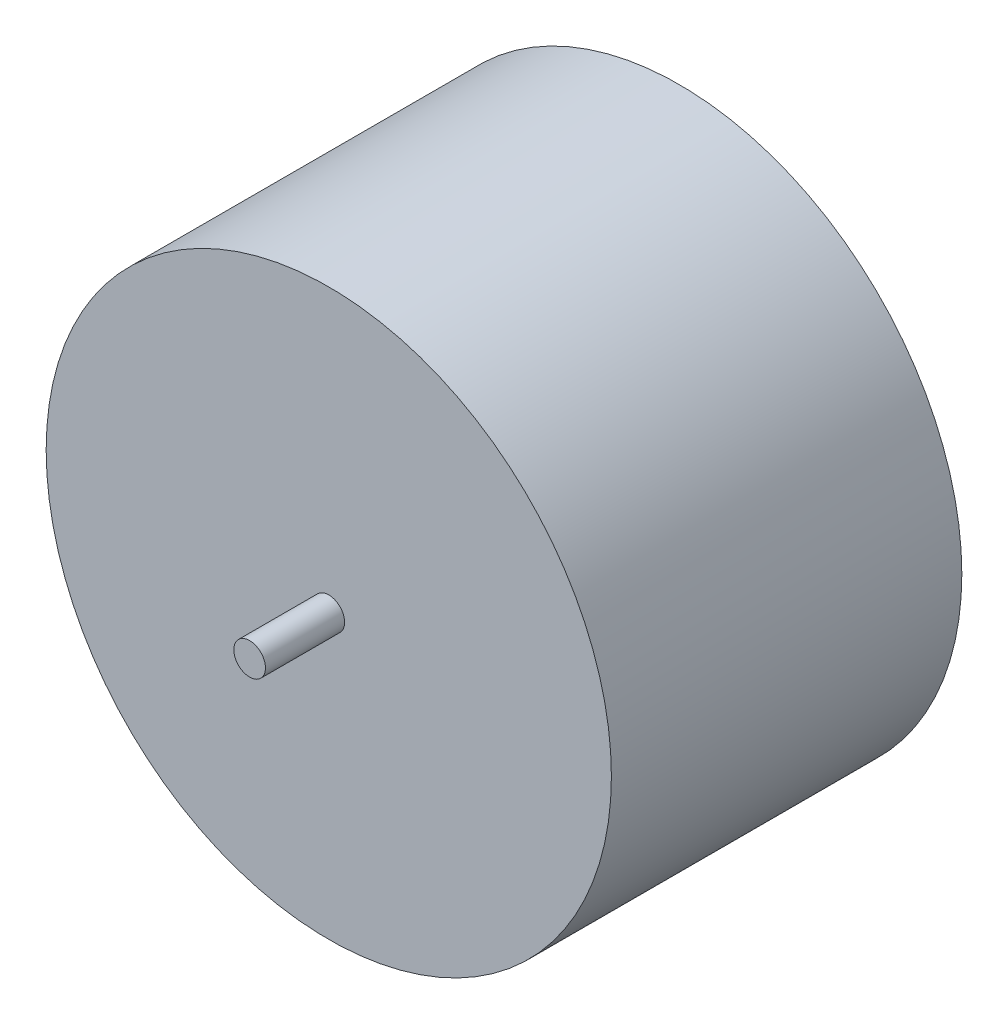
from build123d import *

# Parameters (mm, degrees)
SKETCH1_R           = 125
BOSS_EXTRUDE1_DEPTH = 155
SKETCH2_R           = 7
BOSS_EXTRUDE2_DEPTH = 35
SKETCH3_R           = 7
BOSS_EXTRUDE3_DEPTH = 35


with BuildPart() as part:
    # Sketch1 → Boss-Extrude1 (new body)
    with BuildSketch(Plane.XY):
        Circle(SKETCH1_R)
    extrude(amount=BOSS_EXTRUDE1_DEPTH)

    # Sketch2 → Boss-Extrude2 (add)
    with BuildSketch(Plane.XY.offset(155)):
        Circle(SKETCH2_R)
    extrude(amount=BOSS_EXTRUDE2_DEPTH)

    # Sketch3 → Boss-Extrude3 (add)
    with BuildSketch(Plane(origin=(0, 0, 0), x_dir=(-1, 0, 0), z_dir=(0, 0, -1))):
        Circle(SKETCH3_R)
    extrude(amount=BOSS_EXTRUDE3_DEPTH)


solid = part.part
